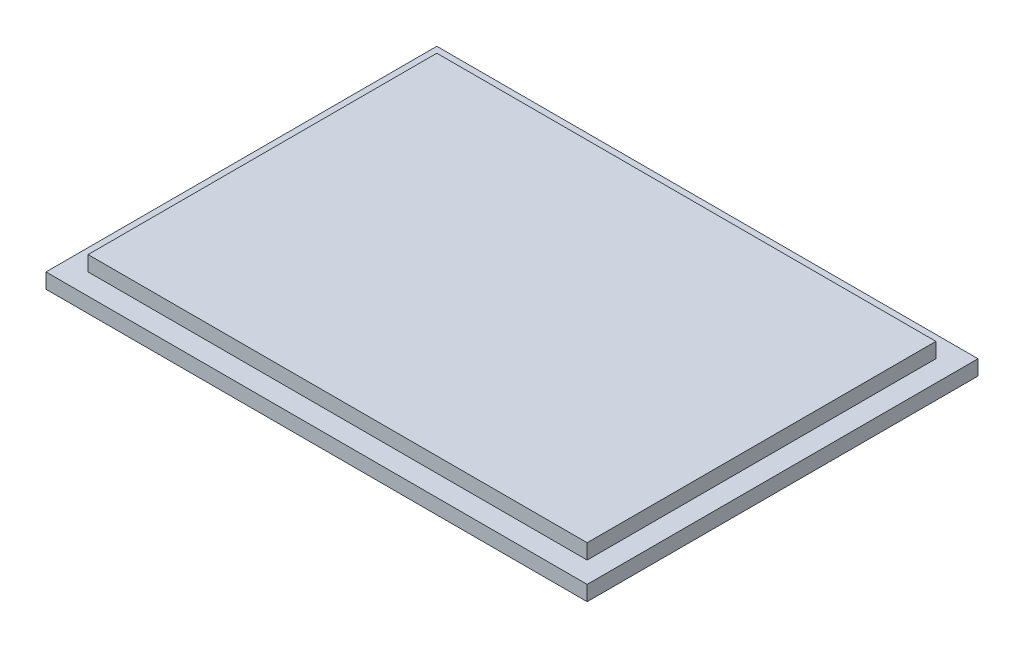
from build123d import *

# Parameters (mm, degrees)
SKETCH_1_W      = 36
SKETCH_1_H      = 26
EXTRUDE_1_DEPTH = 1
SKETCH_3_W      = 33.2
SKETCH_3_H      = 23.2
EXTRUDE_2_DEPTH = 1


with BuildPart() as part:
    # 草图1 → 凸台-拉伸1 (new body)
    with BuildSketch(Plane(origin=(0, 0, 0), x_dir=(1, 0, 0), z_dir=(0, 1, 0))):
        Rectangle(SKETCH_1_W, SKETCH_1_H)
    extrude(amount=-EXTRUDE_1_DEPTH)

    # 草图3 → 凸台-拉伸2 (add)
    with BuildSketch(Plane(origin=(0, 0, 0), x_dir=(1, 0, 0), z_dir=(0, 1, 0))):
        Rectangle(SKETCH_3_W, SKETCH_3_H)
    extrude(amount=EXTRUDE_2_DEPTH)


solid = part.part
